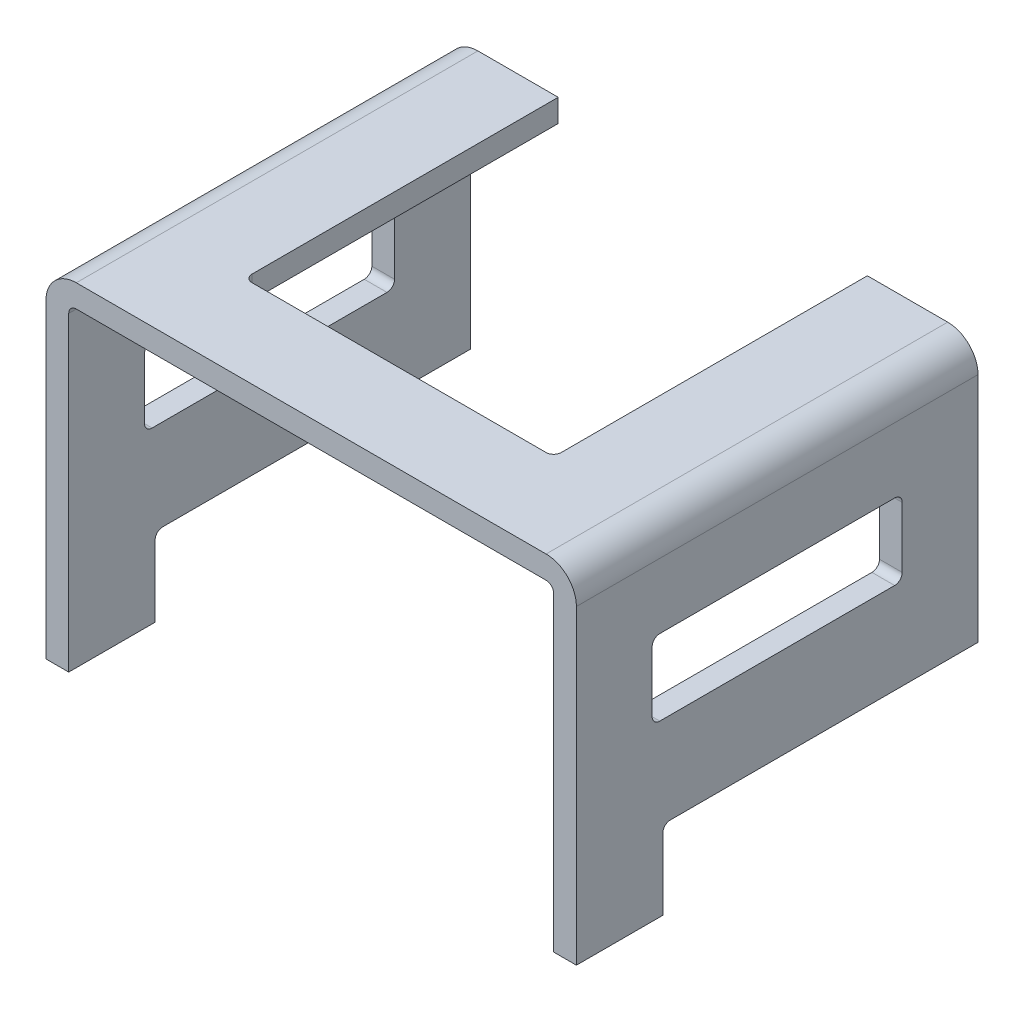
from build123d import *

# Parameters (mm, degrees)
SKETCH1_W           = 35
SKETCH1_H           = 26.5
BOSS_EXTRUDE1_DEPTH = 22.5
SKETCH2_W           = 32
SKETCH2_H           = 21
CUT_EXTRUDE1_DEPTH  = 27.5
SKETCH3_W           = 20.8
SKETCH3_H           = 5.2
CUT_EXTRUDE2_DEPTH  = 2.5
SKETCH4_W           = 20.4
SKETCH4_H           = 20.7
CUT_EXTRUDE3_DEPTH  = 2.5
SKETCH5_W           = 20.8
SKETCH5_H           = 5.2
CUT_EXTRUDE4_DEPTH  = 2.5
FILLET1_R           = 0.5
FILLET2_R           = 2
SKETCH6_W           = 16.5
SKETCH6_H           = 5
CUT_EXTRUDE5_DEPTH  = 35
FILLET3_R           = 0.5


with BuildPart() as part:
    # Sketch1 → Boss-Extrude1 (new body)
    with BuildSketch(Plane(origin=(0, 14, 0), x_dir=(1, 0, 0), z_dir=(0, 1, 0))):
        with Locations((0, -2.75)):
            Rectangle(SKETCH1_W, SKETCH1_H)
    extrude(amount=-BOSS_EXTRUDE1_DEPTH)

    # Sketch2 → Cut-Extrude1 (cut, through all)
    with BuildSketch(Plane.XY.offset(16)):
        with Locations((0, 2)):
            Rectangle(SKETCH2_W, SKETCH2_H)
    extrude(amount=-CUT_EXTRUDE1_DEPTH, mode=Mode.SUBTRACT)

    # Sketch3 → Cut-Extrude2 (cut, through all)
    with BuildSketch(Plane.ZY.offset(-16)):
        with Locations((-0.1, -5.9)):
            Rectangle(SKETCH3_W, SKETCH3_H)
    extrude(amount=-CUT_EXTRUDE2_DEPTH, mode=Mode.SUBTRACT)

    # Sketch4 → Cut-Extrude3 (cut, through all)
    with BuildSketch(Plane.XZ.offset(-12.5)):
        with Locations((0, -0.15)):
            Rectangle(SKETCH4_W, SKETCH4_H)
    extrude(amount=-CUT_EXTRUDE3_DEPTH, mode=Mode.SUBTRACT)

    # Sketch5 → Cut-Extrude4 (cut, through all)
    with BuildSketch(Plane(origin=(-16, 0, 0), x_dir=(0, 0, -1), z_dir=(1, 0, 0))):
        with Locations((0.1, -5.9)):
            Rectangle(SKETCH5_W, SKETCH5_H)
    extrude(amount=-CUT_EXTRUDE4_DEPTH, mode=Mode.SUBTRACT)

    # Fillet1
    fillet1_edges = [part.edges().sort_by_distance(p)[0] for p in [
        (-16, 12.5, 2.75),
        (16, 12.5, 2.75),
    ]]
    fillet(fillet1_edges, radius=FILLET1_R)

    # Fillet2
    fillet2_edges = [part.edges().sort_by_distance(p)[0] for p in [
        (-17.5, 14, 2.75),
        (17.5, 14, 2.75),
    ]]
    fillet(fillet2_edges, radius=FILLET2_R)

    # Sketch6 → Cut-Extrude5 (cut)
    with BuildSketch(Plane(origin=(17.5, 0, 0), x_dir=(0, 0, -1), z_dir=(1, 0, 0))):
        with Locations((-2.75, 5.2)):
            Rectangle(SKETCH6_W, SKETCH6_H)
    extrude(amount=-CUT_EXTRUDE5_DEPTH, mode=Mode.SUBTRACT)

    # Fillet3
    fillet3_edges = [part.edges().sort_by_distance(p)[0] for p in [
        (-16.75, 2.7, 11),
        (16.75, 2.7, 11),
        (-16.75, 7.7, 11),
        (16.75, 7.7, 11),
        (-16.75, 7.7, -5.5),
        (16.75, 7.7, -5.5),
        (-16.75, 2.7, -5.5),
        (16.75, 2.7, -5.5),
        (16.75, -3.3, 10.3),
        (-10.2, 13.25, 10.2),
        (10.2, 13.25, 10.2),
        (-16.75, -3.3, 10.3),
    ]]
    fillet(fillet3_edges, radius=FILLET3_R)


solid = part.part
